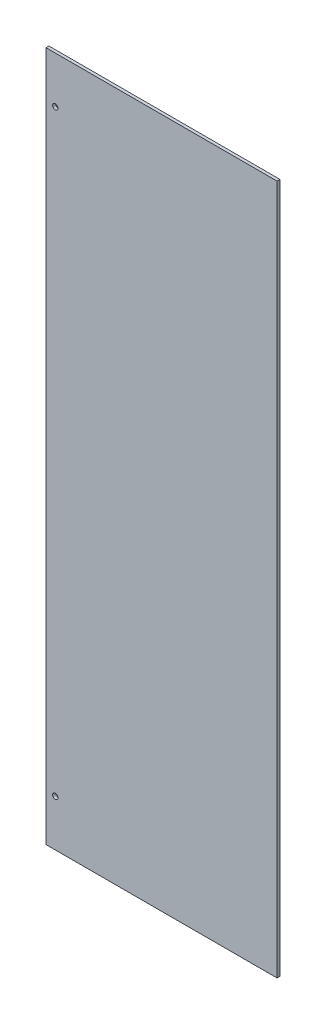
from build123d import *

# Parameters (mm, degrees)
SKETCH1_W           = 126.0475
SKETCH1_H           = 376.555
BOSS_EXTRUDE1_DEPTH = 1.5875
SKETCH2_R           = 1.4605
CUT_EXTRUDE1_DEPTH  = 6.35
LPATTERN1_COUNT     = 2
LPATTERN1_PITCH     = 325.755


with BuildPart() as part:
    # Sketch1 → Boss-Extrude1 (new body)
    with BuildSketch(Plane.XY):
        with Locations((63.02375, 188.2775)):
            Rectangle(SKETCH1_W, SKETCH1_H)
    extrude(amount=BOSS_EXTRUDE1_DEPTH)

    # Sketch2 → Cut-Extrude1 (cut)
    with BuildSketch(Plane.XY.offset(1.5875)):
        with Locations((5.08, 351.155)):
            Circle(SKETCH2_R)
    cut_extrude1 = extrude(amount=-CUT_EXTRUDE1_DEPTH, mode=Mode.SUBTRACT)

    # LPattern1: Cut-Extrude1 ×2
    with Locations(*[(0, -i * LPATTERN1_PITCH, 0) for i in range(1, LPATTERN1_COUNT)]):
        add(cut_extrude1, mode=Mode.SUBTRACT)


solid = part.part
